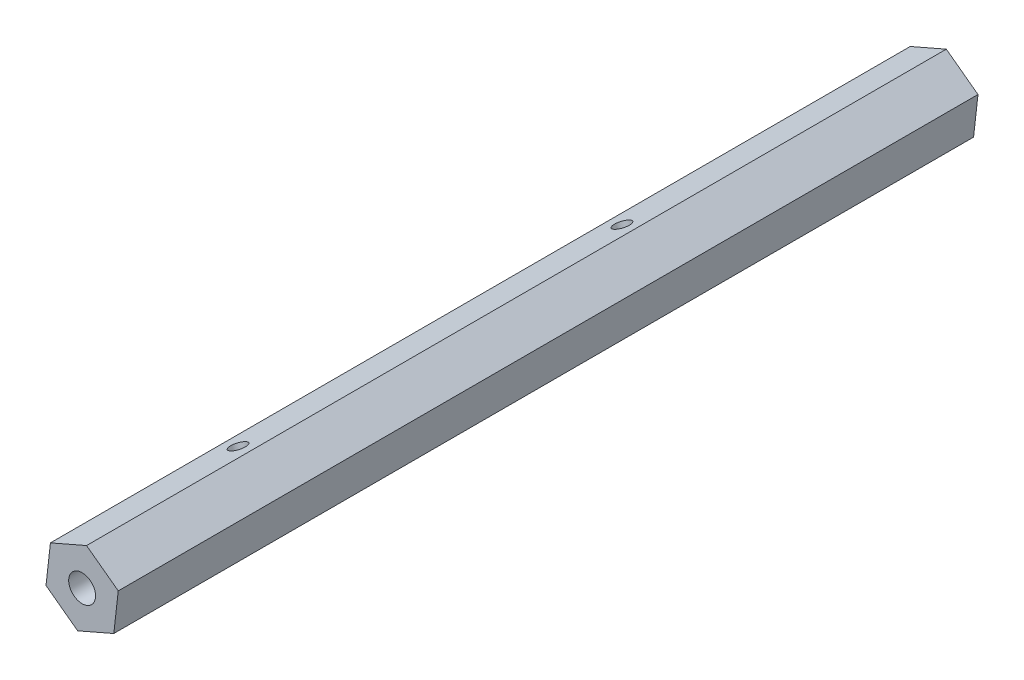
from build123d import *

# Parameters (mm, degrees)
ESBO_O1_R                = 2.5
RESSALTO_EXTRUS_O1_DEPTH = 160
ESBO_O2_R                = 1.5
CORTE_EXTRUS_O1_DEPTH    = 16.714243329
ESBO_O3_R                = 1.5
CORTE_EXTRUS_O2_DEPTH    = 16.714243329


with BuildPart() as part:
    # Esboço1 → Ressalto-extrusão1 (new body)
    with BuildSketch(Plane.XY):
        Polygon((5.897209639, -4.357321633), (6.722156046, 2.928472542), (0.824946407, 7.285794175), (-5.897209639, 4.357321633), (-6.722156046, -2.928472542), (-0.824946407, -7.285794175), align=None)
        Circle(ESBO_O1_R, mode=Mode.SUBTRACT)
    extrude(amount=RESSALTO_EXTRUS_O1_DEPTH)

    # Esboço2 → Corte-extrusão1 (cut, through all)
    with BuildSketch(Plane(origin=(-2.536131616, 5.821557904, 0), x_dir=(0.916780772, 0.399390806, 0), z_dir=(-0.399390806, 0.916780772, 0))):
        with Locations((0, -57)):
            Circle(ESBO_O2_R)
    extrude(amount=-CORTE_EXTRUS_O1_DEPTH, mode=Mode.SUBTRACT)

    # Esboço3 → Corte-extrusão2 (cut, through all)
    with BuildSketch(Plane(origin=(-2.536131616, 5.821557904, 0), x_dir=(0.916780772, 0.399390806, 0), z_dir=(-0.399390806, 0.916780772, 0))):
        with Locations((0, -128.44)):
            Circle(ESBO_O3_R)
    extrude(amount=-CORTE_EXTRUS_O2_DEPTH, mode=Mode.SUBTRACT)


solid = part.part
